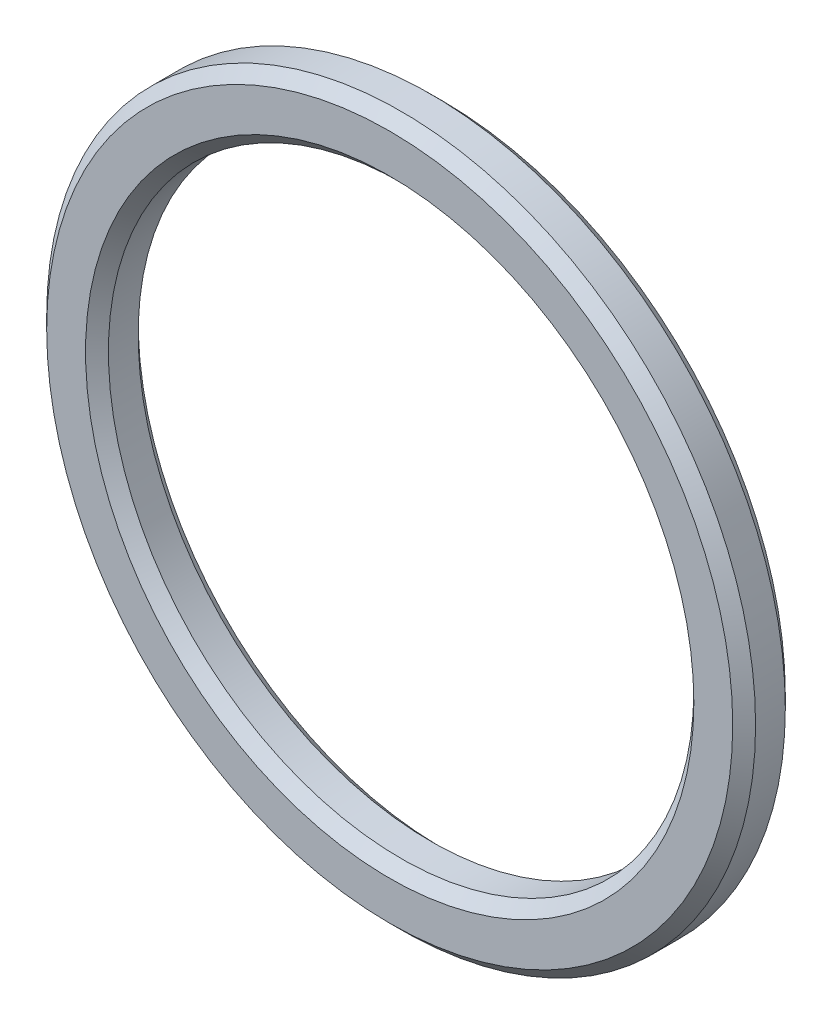
from build123d import *

# Parameters (mm, degrees)
SKETCH1_R           = 15.5
SKETCH1_R_2         = 12.8
BOSS_EXTRUDE1_DEPTH = 2.3
CHAMFER1_SIZE       = 0.5


with BuildPart() as part:
    # Sketch1 → Boss-Extrude1 (new body)
    with BuildSketch(Plane.XY):
        Circle(SKETCH1_R)
        Circle(SKETCH1_R_2, mode=Mode.SUBTRACT)
    extrude(amount=BOSS_EXTRUDE1_DEPTH)

    # Chamfer1
    chamfer1_edges = [part.edges().sort_by_distance(p)[0] for p in [
        (-15.5, 0, 0),
        (-15.5, 0, 2.3),
        (-12.8, 0, 0),
        (-12.8, 0, 2.3),
    ]]
    chamfer(chamfer1_edges, length=CHAMFER1_SIZE)


solid = part.part
